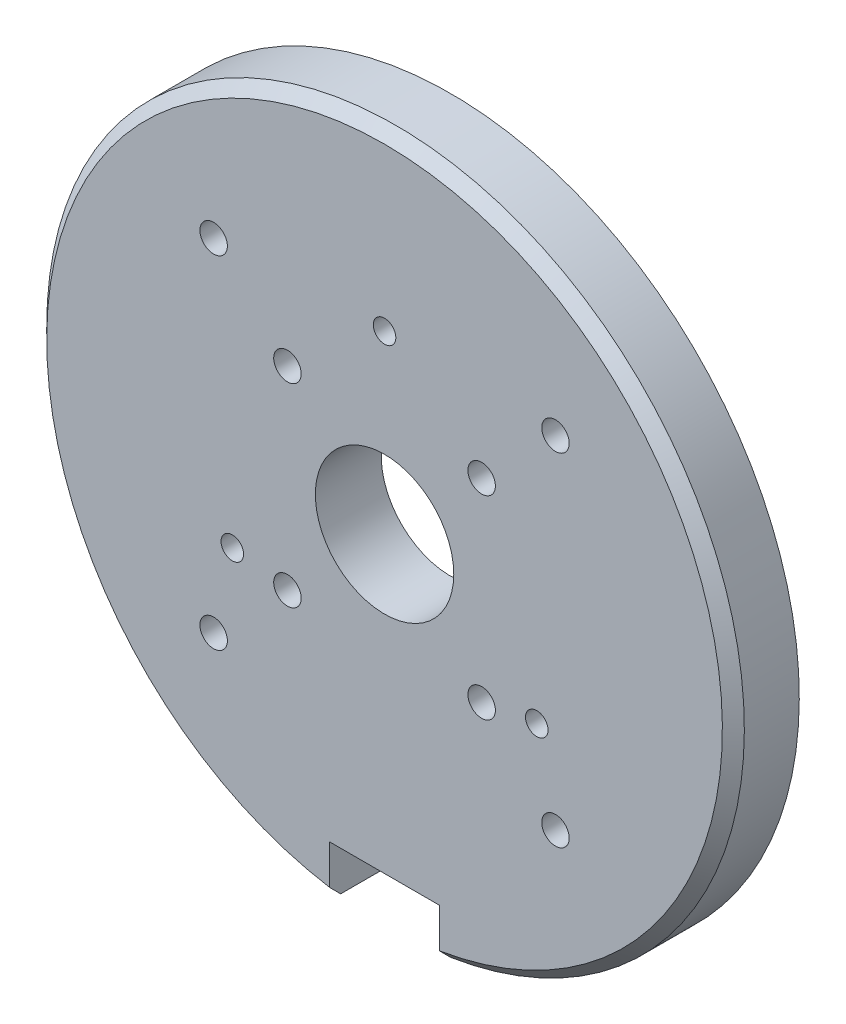
from build123d import *

# Parameters (mm, degrees)
SKETCH_1_R          = 31.75
EXTRUDE_1_DEPTH     = 6
SKETCH_2_W          = 10
SKETCH_2_H          = 10
CUT_EXTRUDE_1_DEPTH = 7
M2_5X0_451_D        = 2.05
M3X0_51_D           = 2.5
SKETCH_8_R          = 6.3
CUT_EXTRUDE_2_DEPTH = 7
CHAMFER_1_SIZE      = 1


with BuildPart() as part:
    # Эскиз1 → Бобышка-Вытянуть1 (new body)
    with BuildSketch(Plane.XY):
        Circle(SKETCH_1_R)
    extrude(amount=EXTRUDE_1_DEPTH)

    # Эскиз2 → Вырез-Вытянуть1 (cut, through all)
    with BuildSketch(Plane.XY.offset(6)):
        with Locations((0, -31.75)):
            Rectangle(SKETCH_2_W, SKETCH_2_H)
    extrude(amount=-CUT_EXTRUDE_1_DEPTH, mode=Mode.SUBTRACT)

    # Отверстие обработанное метчиком M2.5x0.451 (through all)
    with Locations(Plane.XY.offset(6)):
        with Locations((0, 16), (13.856406461, -8), (-13.856406461, -8)):
            Hole(M2_5X0_451_D / 2)

    # Отверстие обработанное метчиком M3x0.51 (through all)
    with Locations(Plane.XY.offset(6)):
        with Locations((-15.556349186, 15.556349186), (-15.556349186, -15.556349186), (15.556349186, -15.556349186), (15.556349186, 15.556349186), (8.838834765, 8.838834765), (-8.838834765, 8.838834765), (-8.838834765, -8.838834765), (8.838834765, -8.838834765)):
            Hole(M3X0_51_D / 2)

    # Эскиз8 → Вырез-Вытянуть2 (cut, through all)
    with BuildSketch(Plane.XY.offset(6)):
        Circle(SKETCH_8_R)
    extrude(amount=-CUT_EXTRUDE_2_DEPTH, mode=Mode.SUBTRACT)

    # Фаска1
    chamfer_1_edges = [part.edges().sort_by_distance(p)[0] for p in [
        (0, 31.75, 6),
    ]]
    chamfer(chamfer_1_edges, length=CHAMFER_1_SIZE)


solid = part.part
